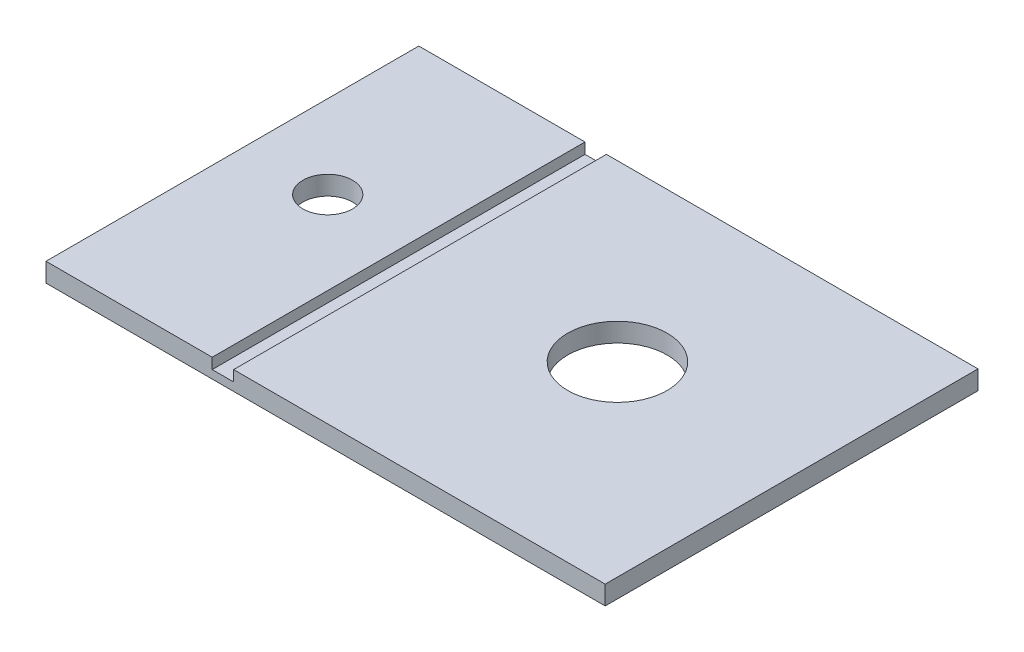
from build123d import *

# Parameters (mm, degrees)
ESQUISSE1_W             = 450
ESQUISSE1_H             = 15.25
BOSS_EXTRU_1_DEPTH      = 300
ESQUISSE2_W             = 17.25
ESQUISSE2_H             = 300
ENL_V_MAT_EXTRU_1_DEPTH = 8.625
ENL_V_MAT_EXTRU_2_REACH = 17.25
ESQUISSE3_R             = 40
ESQUISSE3_R_2           = 20


with BuildPart() as part:
    # Esquisse1 → Boss.-Extru.1 (new body)
    with BuildSketch(Plane.XY):
        with Locations((-225, 52.688864629)):
            Rectangle(ESQUISSE1_W, ESQUISSE1_H)
    extrude(amount=BOSS_EXTRU_1_DEPTH)

    # Esquisse2 → Enlèv. mat.-Extru.1 (cut)
    with BuildSketch(Plane(origin=(0, 60.313864629, 0), x_dir=(1, 0, 0), z_dir=(0, 1, 0))):
        with Locations((-307.625, -150)):
            Rectangle(ESQUISSE2_W, ESQUISSE2_H)
    extrude(amount=-ENL_V_MAT_EXTRU_1_DEPTH, mode=Mode.SUBTRACT)

    # Esquisse3 → Enlèv. mat.-Extru.2 (cut, up to next)
    with BuildSketch(Plane(origin=(0, 60.313864629, 0), x_dir=(1, 0, 0), z_dir=(0, 1, 0)), mode=Mode.PRIVATE) as enl_v_mat_extru_2_sk1:
        with Locations((-150, -140.161341078)):
            Circle(ESQUISSE3_R)
    enl_v_mat_extru_2_tool1 = extrude(enl_v_mat_extru_2_sk1.sketch, amount=-ENL_V_MAT_EXTRU_2_REACH, mode=Mode.PRIVATE) & part.part
    add(enl_v_mat_extru_2_tool1.solids().sort_by_distance((-150, 60.313865, 140.161341))[0], mode=Mode.SUBTRACT)
    # Esquisse3 → Enlèv. mat.-Extru.2 (cut, up to next)
    with BuildSketch(Plane(origin=(0, 60.313864629, 0), x_dir=(1, 0, 0), z_dir=(0, 1, 0)), mode=Mode.PRIVATE) as enl_v_mat_extru_2_sk2:
        with Locations((-383.125, -140.161341078)):
            Circle(ESQUISSE3_R_2)
    enl_v_mat_extru_2_tool2 = extrude(enl_v_mat_extru_2_sk2.sketch, amount=-ENL_V_MAT_EXTRU_2_REACH, mode=Mode.PRIVATE) & part.part
    add(enl_v_mat_extru_2_tool2.solids().sort_by_distance((-383.125, 60.313865, 140.161341))[0], mode=Mode.SUBTRACT)


solid = part.part
